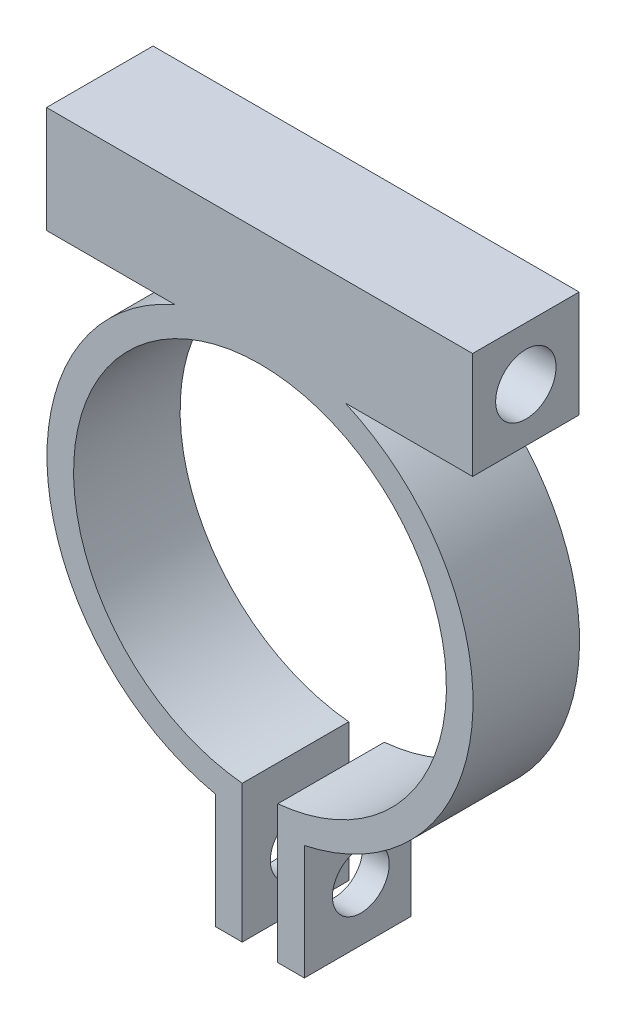
from build123d import *

# Parameters (mm, degrees)
SALIENTE_EXTRUIR1_DEPTH      = 6
TALADRO_DE_MARGEN_PARA_M31_D = 3.4
TALADRO_DE_MARGEN_PARA_M32_D = 3.2


with BuildPart() as part:
    # Croquis1 → Saliente-Extruir1 (new body)
    with BuildSketch(Plane.XY):
        with BuildLine():
            Line((11.975508884, 11), (11.975508884, 17))
            Line((11.975508884, 17), (-12.024491116, 17))
            Line((-12.024491116, 17), (-12.024491116, 11))
            Line((-12.024491116, 11), (-4.795831523, 11))
            ThreePointArc((-4.795831523, 11), (-11.939288491, -1.205566393), (-2.5, -11.736694594))
            Line((-2.5, -11.736694594), (-2.5, -18.20187424))
            Line((-2.5, -18.20187424), (-1, -18.20187424))
            Line((-1, -18.20187424), (-1, -10.45227248))
            ThreePointArc((-1, -10.45227248), (0, 10.5), (1, -10.45227248))
            Line((1, -10.45227248), (1, -18.20187424))
            Line((1, -18.20187424), (2.5, -18.20187424))
            Line((2.5, -18.20187424), (2.5, -11.736694594))
            ThreePointArc((2.5, -11.736694594), (11.939288491, -1.205566393), (4.795831523, 11))
            Line((4.795831523, 11), (11.975508884, 11))
        make_face()
    extrude(amount=SALIENTE_EXTRUIR1_DEPTH)

    # Taladro de margen para M31 (through all)
    with Locations(Plane(origin=(11.975508884, 0, 0), x_dir=(0, 0, -1), z_dir=(1, 0, 0))):
        with Locations((-3, 14)):
            Hole(TALADRO_DE_MARGEN_PARA_M31_D / 2)

    # Taladro de margen para M32 (through all)
    with Locations(Plane.ZY.offset(2.5)):
        with Locations((2.820532603, -15.023895907)):
            Hole(TALADRO_DE_MARGEN_PARA_M32_D / 2)


solid = part.part
